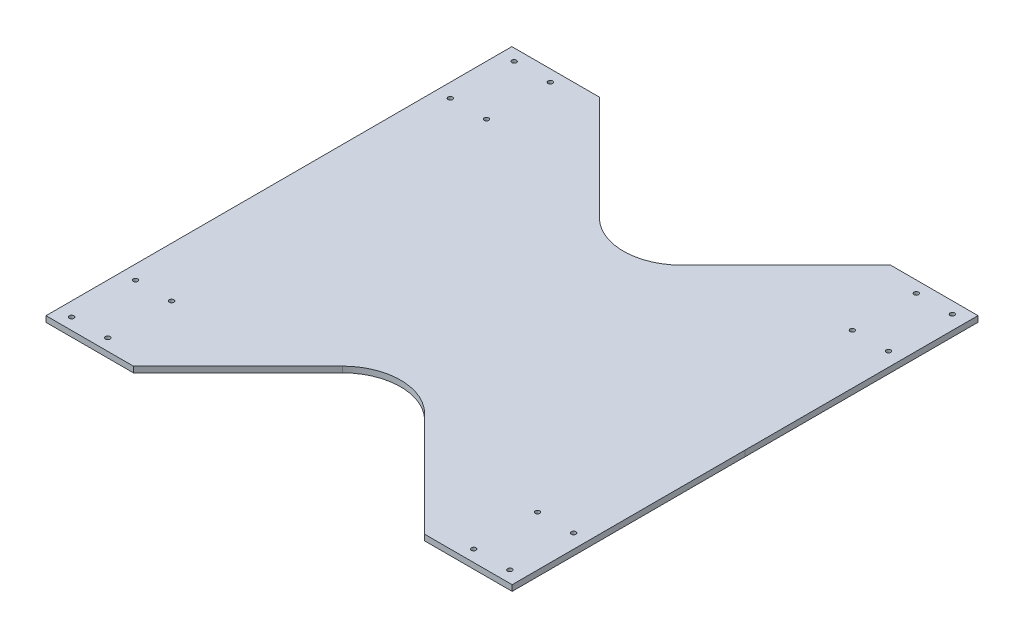
from build123d import *

# Parameters (mm, degrees)
SKETCH1_R           = 1.95
BOSS_EXTRUDE1_DEPTH = 5
FILLET1_R           = 50


with BuildPart() as part:
    # Sketch1 → Boss-Extrude1 (new body)
    with BuildSketch(Plane(origin=(0, 0, 0), x_dir=(1, 0, 0), z_dir=(0, 1, 0))):
        Polygon((-171.385103045, 78.719364296), (-46.385103045, 203.765478515), (28.614896955, 203.765478515), (28.614896955, 3.765478515), (28.707125389, -196.23450022), (-46.292866637, -196.269085883), (-171.350517383, -71.28062773), (-296.350517383, -196.326741949), (-371.350517383, -196.326741949), (-371.350517383, 3.673258051), (-371.442745817, 203.673236785), (-296.442753791, 203.707822448), align=None)
        with Locations((16.614896955, 193.765478515)):
            Circle(SKETCH1_R, mode=Mode.SUBTRACT)
        with Locations((-14.385103045, 193.765478515)):
            Circle(SKETCH1_R, mode=Mode.SUBTRACT)
        with Locations((-14.385103045, 138.925478515)):
            Circle(SKETCH1_R, mode=Mode.SUBTRACT)
        with Locations((16.614896955, 138.925478515)):
            Circle(SKETCH1_R, mode=Mode.SUBTRACT)
        with Locations((16.677226206, -131.40004082)):
            Circle(SKETCH1_R, mode=Mode.SUBTRACT)
        with Locations((-14.322770498, -131.414336227)):
            Circle(SKETCH1_R, mode=Mode.SUBTRACT)
        with Locations((16.702515243, -186.240034989)):
            Circle(SKETCH1_R, mode=Mode.SUBTRACT)
        with Locations((-14.297481461, -186.254330396)):
            Circle(SKETCH1_R, mode=Mode.SUBTRACT)
        with Locations((-328.350517383, -186.326741949)):
            Circle(SKETCH1_R, mode=Mode.SUBTRACT)
        with Locations((-359.350517383, -186.326741949)):
            Circle(SKETCH1_R, mode=Mode.SUBTRACT)
        with Locations((-328.350517383, -131.486741949)):
            Circle(SKETCH1_R, mode=Mode.SUBTRACT)
        with Locations((-359.350517383, -131.486741949)):
            Circle(SKETCH1_R, mode=Mode.SUBTRACT)
        with Locations((-359.412846634, 138.838777386)):
            Circle(SKETCH1_R, mode=Mode.SUBTRACT)
        with Locations((-328.41284993, 138.853072793)):
            Circle(SKETCH1_R, mode=Mode.SUBTRACT)
        with Locations((-328.438138967, 193.693066962)):
            Circle(SKETCH1_R, mode=Mode.SUBTRACT)
        with Locations((-359.438135671, 193.678771555)):
            Circle(SKETCH1_R, mode=Mode.SUBTRACT)
    extrude(amount=BOSS_EXTRUDE1_DEPTH)

    # Fillet1
    fillet1_edges = [part.edges().sort_by_distance(p)[0] for p in [
        (-171.385103045, 2.5, -78.719364296),
        (-171.350517383, 2.5, 71.28062773),
    ]]
    fillet(fillet1_edges, radius=FILLET1_R)


solid = part.part
